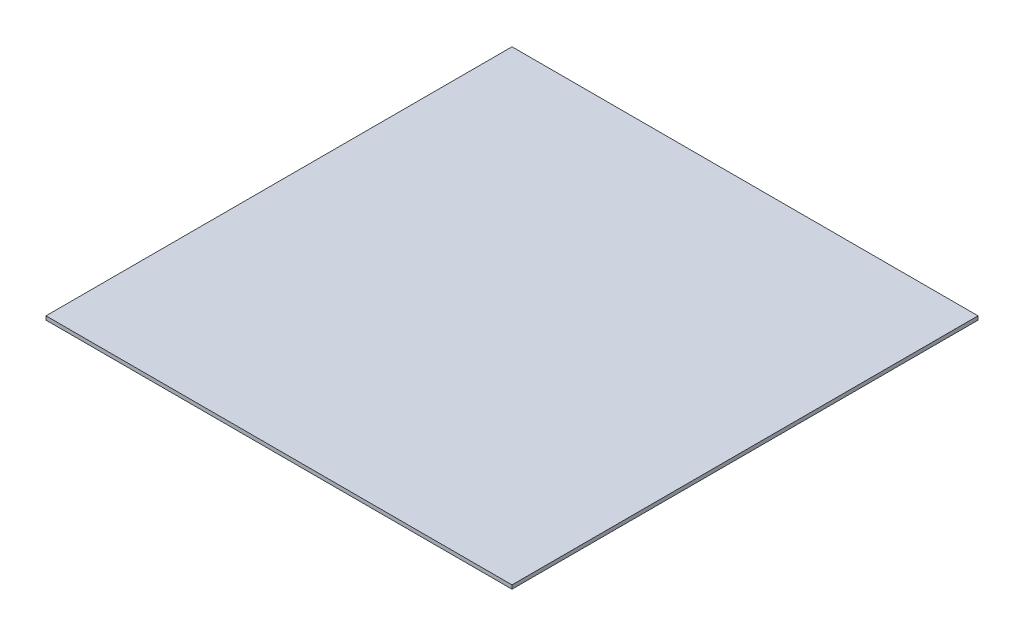
from build123d import *

# Parameters (mm, degrees)
SKETCH1_W           = 370
SKETCH1_H           = 370
BOSS_EXTRUDE1_DEPTH = 3


with BuildPart() as part:
    # Sketch1 → Boss-Extrude1 (new body)
    with BuildSketch(Plane(origin=(0, 0, 0), x_dir=(1, 0, 0), z_dir=(0, 1, 0))):
        Rectangle(SKETCH1_W, SKETCH1_H)
    extrude(amount=BOSS_EXTRUDE1_DEPTH)


solid = part.part
